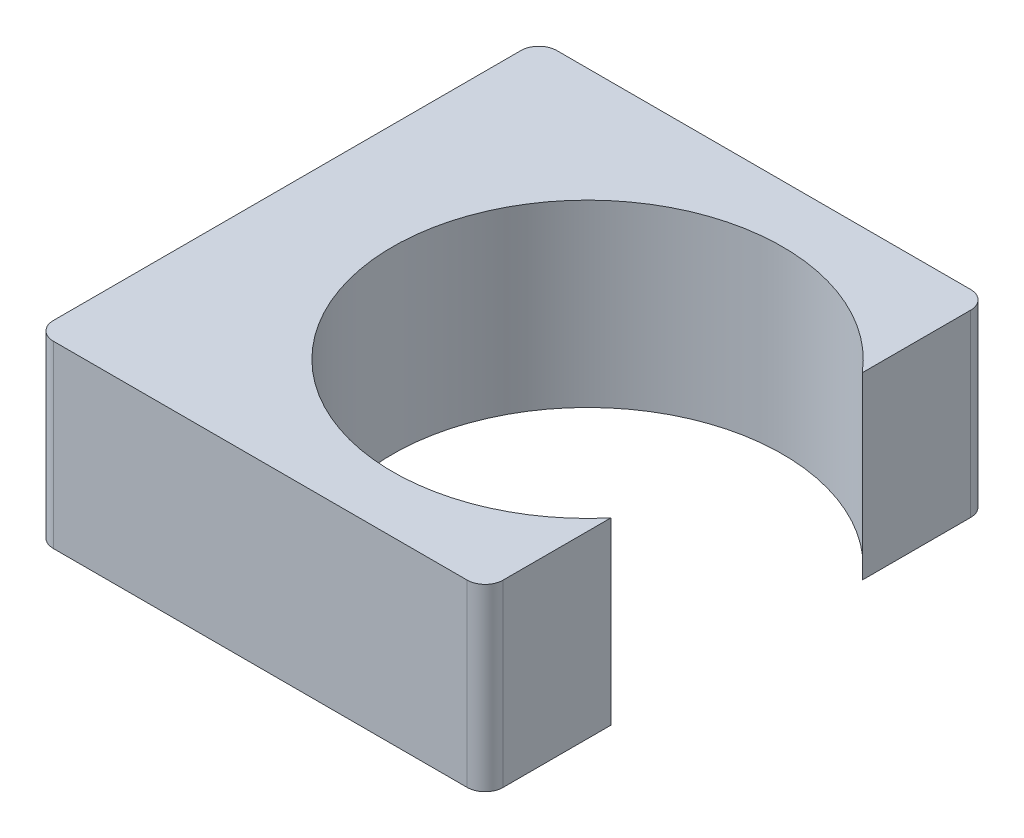
from build123d import *

# Parameters (mm, degrees)
BOSS_EXTRUDE1_DEPTH = 25.4


with BuildPart() as part:
    # Sketch1 → Boss-Extrude1 (new body)
    with BuildSketch(Plane(origin=(0, 0, 0), x_dir=(1, 0, 0), z_dir=(0, 1, 0))):
        with BuildLine():
            Line((18.533658611, 35.641367486), (-39.99048208, 35.641367486))
            ThreePointArc((-39.99048208, 35.641367486), (-41.786533304, 34.89741871), (-42.53048208, 33.101367486))
            Line((-42.53048208, 33.101367486), (-42.53048208, -33.022533273))
            ThreePointArc((-42.53048208, -33.022533273), (-41.786533304, -34.818584498), (-39.99048208, -35.562533273))
            Line((-39.99048208, -35.562533273), (18.533658611, -35.562533273))
            ThreePointArc((18.533658611, -35.562533273), (20.329709835, -34.818584498), (21.073658611, -33.022533273))
            Line((21.073658611, -33.022533273), (21.073658611, -17.78))
            ThreePointArc((21.073658611, -17.78), (-27.572223111, 0), (21.073658611, 17.78))
            Line((21.073658611, 17.78), (21.073658611, 33.101367486))
            ThreePointArc((21.073658611, 33.101367486), (20.329709835, 34.89741871), (18.533658611, 35.641367486))
        make_face()
    extrude(amount=BOSS_EXTRUDE1_DEPTH)


solid = part.part
